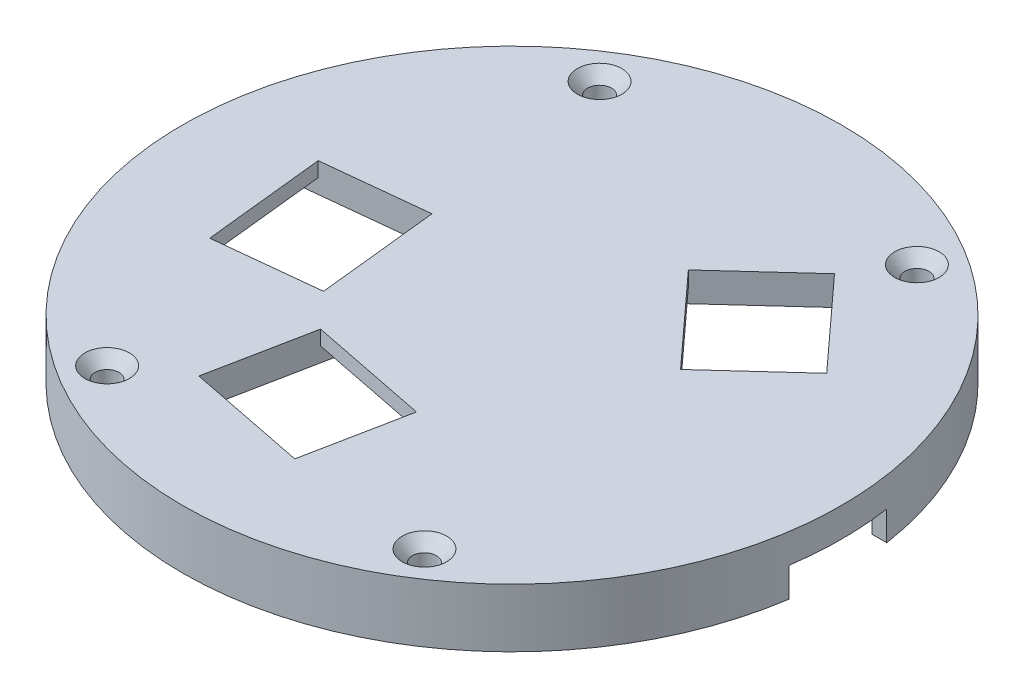
from build123d import *

# Parameters (mm, degrees)
SKETCH2_R                                         = 67.5
PALM_BASE_DEPTH                                   = 12
BOTTOM_SURFACE_REMOVED_T                          = -6
THROUGH_HOLE_FOR_FINGER_BASE_REACH                = 98.211
FINGER_BASE_CUT_OFFSET_FROM_SURFACE_REACH         = 101.211
FINGER_START                                      = -3
SKETCH4_R                                         = 64.5
SIDE_THICKNESS_CUT_DEPTH                          = 6
CSK_FOR_8_FLAT_HEAD_SOCKET_CAP_SCREW1_D           = 4.9149
CSK_FOR_8_FLAT_HEAD_SOCKET_CAP_SCREW1_CSINK_D     = 9.1186
CSK_FOR_8_FLAT_HEAD_SOCKET_CAP_SCREW1_CSINK_ANGLE = 82
SLOT_FOR_PALM_BOTTOM_REACH                        = 98.211
SLOT_FOR_PALM_BOTTOM_END_RADIUS                   = 67.5
SKETCH9_W                                         = 20
SKETCH9_H                                         = 6
SLOT_FOR_PALM_BOTTOM_DIRECTION_2_REACH            = 98.211
SLOT_FOR_PALM_BOTTOM_DIRECTION_2_END_RADIUS       = 67.5


with BuildPart() as part:
    # Sketch2 → Palm base (new body)
    with BuildSketch(Plane(origin=(0, 0, 0), x_dir=(1, 0, 0), z_dir=(0, 1, 0))):
        with Locations(Location((0, 0, 0), (0, 0, 270))):
            Circle(SKETCH2_R)
    extrude(amount=-PALM_BASE_DEPTH)

    # Bottom surface removed
    bottom_surface_removed_openings = [part.faces().sort_by_distance(p)[0] for p in [
        (0, -12, 0),
    ]]
    offset(amount=BOTTOM_SURFACE_REMOVED_T, openings=bottom_surface_removed_openings, kind=Kind.INTERSECTION)

    # Sketch3 → Through hole for finger base (cut, up to next)
    with BuildSketch(Plane(origin=(0, 0, 0), x_dir=(1, 0, 0), z_dir=(0, 1, 0)), mode=Mode.PRIVATE) as through_hole_for_finger_base_sk1:
        Polygon((25.678953914, 40.377684751), (42.53720785, 21.916935194), (26.889876526, 7.627879157), (10.031622589, 26.088628715), align=None)
    through_hole_for_finger_base_tool1 = extrude(through_hole_for_finger_base_sk1.sketch, amount=-THROUGH_HOLE_FOR_FINGER_BASE_REACH, mode=Mode.PRIVATE) & part.part
    # Sketch3 → Through hole for finger base (cut, up to next)
    with BuildSketch(Plane(origin=(0, 0, 0), x_dir=(1, 0, 0), z_dir=(0, 1, 0)), mode=Mode.PRIVATE) as through_hole_for_finger_base_sk2:
        Polygon((7.379432661, -26.959116707), (-17.139633769, -22.079016153), (-21.276006998, -42.861376859), (3.243059431, -47.741477412), align=None)
    through_hole_for_finger_base_tool2 = extrude(through_hole_for_finger_base_sk2.sketch, amount=-THROUGH_HOLE_FOR_FINGER_BASE_REACH, mode=Mode.PRIVATE) & part.part
    # Sketch3 → Through hole for finger base (cut, up to next)
    with BuildSketch(Plane(origin=(0, 0, 0), x_dir=(1, 0, 0), z_dir=(0, 1, 0)), mode=Mode.PRIVATE) as through_hole_for_finger_base_sk3:
        Polygon((-26.18008314, 9.790467137), (-23.540423594, -15.06978623), (-44.611974348, -17.307161662), (-47.251633894, 7.553091705), align=None)
    through_hole_for_finger_base_tool3 = extrude(through_hole_for_finger_base_sk3.sketch, amount=-THROUGH_HOLE_FOR_FINGER_BASE_REACH, mode=Mode.PRIVATE) & part.part
    add(through_hole_for_finger_base_tool1.solids().sort_by_distance((26.284415, 0, -24.002782))[0], mode=Mode.SUBTRACT)
    add(through_hole_for_finger_base_tool2.solids().sort_by_distance((-6.948287, 0, 34.910247))[0], mode=Mode.SUBTRACT)
    add(through_hole_for_finger_base_tool3.solids().sort_by_distance((-35.396029, 0, 3.758347))[0], mode=Mode.SUBTRACT)

    # Sketch7 → Finger base cut offset from surface (cut, up to next)
    with BuildSketch(Plane(origin=(0, 0, 0), x_dir=(1, 0, 0), z_dir=(0, 1, 0)).offset(FINGER_START), mode=Mode.PRIVATE) as finger_base_cut_offset_from_surface_sk1:
        Polygon((8.179769152, -22.937989812), (-16.339297278, -18.057889258), (-17.139633769, -22.079016153), (7.379432661, -26.959116707), align=None)
    finger_base_cut_offset_from_surface_tool1 = extrude(finger_base_cut_offset_from_surface_sk1.sketch, amount=-FINGER_BASE_CUT_OFFSET_FROM_SURFACE_REACH, mode=Mode.PRIVATE) & part.part
    # Sketch7 → Finger base cut offset from surface (cut, up to next)
    with BuildSketch(Plane(origin=(0, 0, 0), x_dir=(1, 0, 0), z_dir=(0, 1, 0)).offset(FINGER_START), mode=Mode.PRIVATE) as finger_base_cut_offset_from_surface_sk2:
        Polygon((-22.076343489, -46.882503753), (2.442722941, -51.762604307), (3.243059431, -47.741477412), (-21.276006998, -42.861376859), align=None)
    finger_base_cut_offset_from_surface_tool2 = extrude(finger_base_cut_offset_from_surface_sk2.sketch, amount=-FINGER_BASE_CUT_OFFSET_FROM_SURFACE_REACH, mode=Mode.PRIVATE) & part.part
    # Sketch7 → Finger base cut offset from surface (cut, up to next)
    with BuildSketch(Plane(origin=(0, 0, 0), x_dir=(1, 0, 0), z_dir=(0, 1, 0)).offset(FINGER_START), mode=Mode.PRIVATE) as finger_base_cut_offset_from_surface_sk3:
        Polygon((10.031622589, 26.088628715), (7.004059662, 23.323875069), (23.862313598, 4.863125512), (26.889876526, 7.627879157), align=None)
    finger_base_cut_offset_from_surface_tool3 = extrude(finger_base_cut_offset_from_surface_sk3.sketch, amount=-FINGER_BASE_CUT_OFFSET_FROM_SURFACE_REACH, mode=Mode.PRIVATE) & part.part
    # Sketch7 → Finger base cut offset from surface (cut, up to next)
    with BuildSketch(Plane(origin=(0, 0, 0), x_dir=(1, 0, 0), z_dir=(0, 1, 0)).offset(FINGER_START), mode=Mode.PRIVATE) as finger_base_cut_offset_from_surface_sk4:
        Polygon((45.564770778, 24.681688839), (42.53720785, 21.916935194), (25.678953914, 40.377684751), (28.706516842, 43.142438397), align=None)
    finger_base_cut_offset_from_surface_tool4 = extrude(finger_base_cut_offset_from_surface_sk4.sketch, amount=-FINGER_BASE_CUT_OFFSET_FROM_SURFACE_REACH, mode=Mode.PRIVATE) & part.part
    # Sketch7 → Finger base cut offset from surface (cut, up to next)
    with BuildSketch(Plane(origin=(0, 0, 0), x_dir=(1, 0, 0), z_dir=(0, 1, 0)).offset(FINGER_START), mode=Mode.PRIVATE) as finger_base_cut_offset_from_surface_sk5:
        Polygon((-48.6890559, -17.740065828), (-44.611974348, -17.307161662), (-47.251633894, 7.553091705), (-51.328715447, 7.120187539), align=None)
    finger_base_cut_offset_from_surface_tool5 = extrude(finger_base_cut_offset_from_surface_sk5.sketch, amount=-FINGER_BASE_CUT_OFFSET_FROM_SURFACE_REACH, mode=Mode.PRIVATE) & part.part
    # Sketch7 → Finger base cut offset from surface (cut, up to next)
    with BuildSketch(Plane(origin=(0, 0, 0), x_dir=(1, 0, 0), z_dir=(0, 1, 0)).offset(FINGER_START), mode=Mode.PRIVATE) as finger_base_cut_offset_from_surface_sk6:
        Polygon((-23.540423594, -15.06978623), (-26.18008314, 9.790467137), (-22.103001588, 10.223371302), (-19.463342042, -14.636882065), align=None)
    finger_base_cut_offset_from_surface_tool6 = extrude(finger_base_cut_offset_from_surface_sk6.sketch, amount=-FINGER_BASE_CUT_OFFSET_FROM_SURFACE_REACH, mode=Mode.PRIVATE) & part.part
    add(finger_base_cut_offset_from_surface_tool1.solids().sort_by_distance((-4.479932, -3, 22.508503))[0], mode=Mode.SUBTRACT)
    add(finger_base_cut_offset_from_surface_tool2.solids().sort_by_distance((-9.416642, -3, 47.311991))[0], mode=Mode.SUBTRACT)
    add(finger_base_cut_offset_from_surface_tool3.solids().sort_by_distance((16.946968, -3, -15.475877))[0], mode=Mode.SUBTRACT)
    add(finger_base_cut_offset_from_surface_tool4.solids().sort_by_distance((35.621862, -3, -32.529687))[0], mode=Mode.SUBTRACT)
    add(finger_base_cut_offset_from_surface_tool5.solids().sort_by_distance((-47.970345, -3, 5.093487))[0], mode=Mode.SUBTRACT)
    add(finger_base_cut_offset_from_surface_tool6.solids().sort_by_distance((-22.821713, -3, 2.423207))[0], mode=Mode.SUBTRACT)

    # Sketch4 → Side thickness cut (cut)
    with BuildSketch(Plane.XZ.offset(12)):
        with Locations(Location((0, 0, 0), (0, 0, 270))):
            Circle(SKETCH4_R)
    extrude(amount=-SIDE_THICKNESS_CUT_DEPTH, mode=Mode.SUBTRACT)

    # CSK for #8 Flat Head Socket Cap Screw1 (through all)
    with Locations(Plane(origin=(-32.5, 0, -50.435602505), x_dir=(0, 0, 1), z_dir=(0, 1, 0))):
        with Locations((0, 0), (0, 65), (100.87120501, 65), (100.87120501, 0)):
            CounterSinkHole(CSK_FOR_8_FLAT_HEAD_SOCKET_CAP_SCREW1_D / 2, CSK_FOR_8_FLAT_HEAD_SOCKET_CAP_SCREW1_CSINK_D / 2, counter_sink_angle=CSK_FOR_8_FLAT_HEAD_SOCKET_CAP_SCREW1_CSINK_ANGLE)

    # Slot for palm bottom: up to this cylinder (the profile starts inside it)
    slot_for_palm_bottom_end = Plane(origin=(0, -9, 0), z_dir=(0, 1, 0)) * Cylinder(SLOT_FOR_PALM_BOTTOM_END_RADIUS, 332.422, mode=Mode.PRIVATE)
    # Sketch9 → Slot for palm bottom (cut, up to the surface)
    with BuildSketch(Plane(origin=(0, 0, 0), x_dir=(0, 0, -1), z_dir=(1, 0, 0)), mode=Mode.PRIVATE) as slot_for_palm_bottom_sk1:
        with Locations((0, -9)):
            Rectangle(SKETCH9_W, SKETCH9_H)
    slot_for_palm_bottom_tool1 = extrude(slot_for_palm_bottom_sk1.sketch, amount=-SLOT_FOR_PALM_BOTTOM_REACH, mode=Mode.PRIVATE) & slot_for_palm_bottom_end
    add(slot_for_palm_bottom_tool1.solids().sort_by_distance((0, -9, 0))[0], mode=Mode.SUBTRACT)

    # Slot for palm bottom direction 2: up to this cylinder (the profile starts inside it)
    slot_for_palm_bottom_direction_2_end = Plane(origin=(0, -9, 0), z_dir=(0, 1, 0)) * Cylinder(SLOT_FOR_PALM_BOTTOM_DIRECTION_2_END_RADIUS, 332.422, mode=Mode.PRIVATE)
    # Sketch9 → Slot for palm bottom direction 2 (cut, up to the surface)
    with BuildSketch(Plane(origin=(0, 0, 0), x_dir=(0, 0, -1), z_dir=(1, 0, 0)), mode=Mode.PRIVATE) as slot_for_palm_bottom_direction_2_sk1:
        with Locations((0, -9)):
            Rectangle(SKETCH9_W, SKETCH9_H)
    slot_for_palm_bottom_direction_2_tool1 = extrude(slot_for_palm_bottom_direction_2_sk1.sketch, amount=SLOT_FOR_PALM_BOTTOM_DIRECTION_2_REACH, mode=Mode.PRIVATE) & slot_for_palm_bottom_direction_2_end
    add(slot_for_palm_bottom_direction_2_tool1.solids().sort_by_distance((0, -9, 0))[0], mode=Mode.SUBTRACT)


solid = part.part
